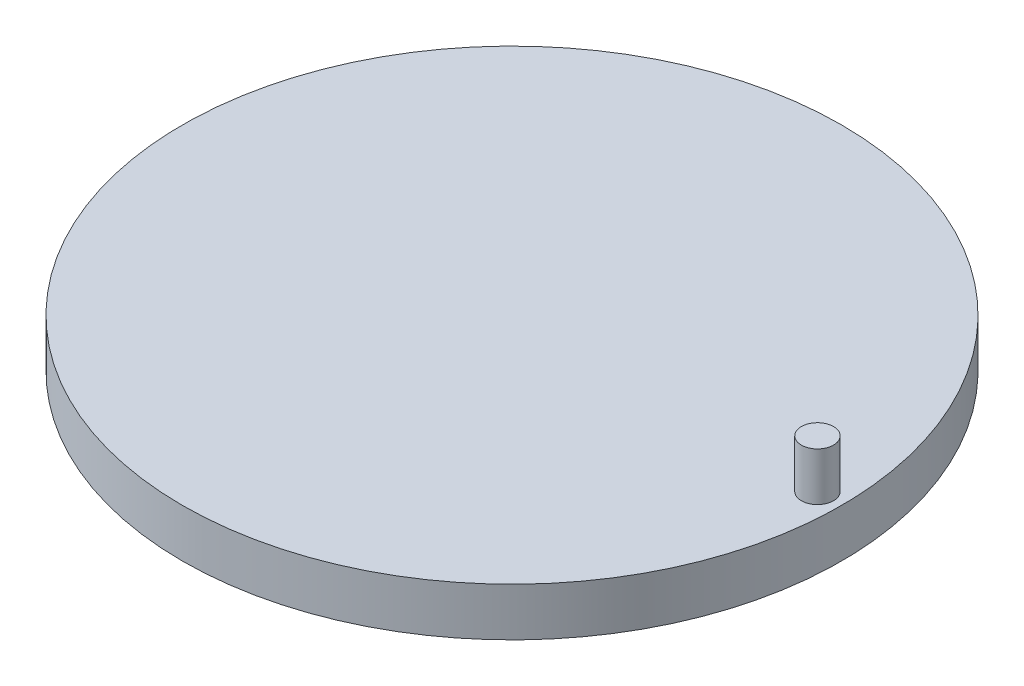
from build123d import *

# Parameters (mm, degrees)
IZIM2_R                     = 20.5
IZIM2_R_2                   = 1
Y_KSEKLIK_EKSTR_ZYON1_DEPTH = 3
IZIM2_3_R                   = 1
Y_KSEKLIK_EKSTR_ZYON2_DEPTH = 6


with BuildPart() as part:
    # Çizim2 → Yükseklik-Ekstrüzyon1 (new body)
    with BuildSketch(Plane(origin=(0, 0, 0), x_dir=(1, 0, 0), z_dir=(0, 1, 0))):
        Circle(IZIM2_R)
        with Locations((19, 0)):
            Circle(IZIM2_R_2, mode=Mode.SUBTRACT)
    extrude(amount=Y_KSEKLIK_EKSTR_ZYON1_DEPTH)

    # Çizim2<3> → Yükseklik-Ekstrüzyon2 (add)
    with BuildSketch(Plane(origin=(0, 0, 0), x_dir=(1, 0, 0), z_dir=(0, 1, 0))):
        with Locations((19, 0)):
            Circle(IZIM2_3_R)
    extrude(amount=Y_KSEKLIK_EKSTR_ZYON2_DEPTH)


solid = part.part
